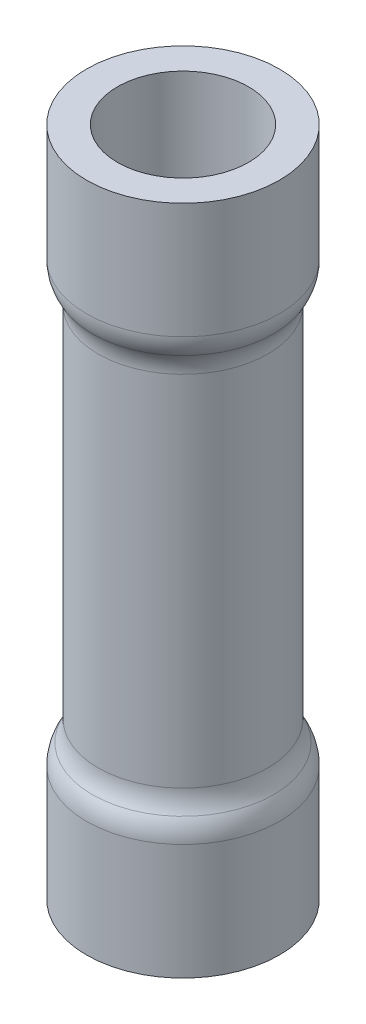
from build123d import *


with BuildPart() as part:
    # Sketch1 → Revolve-Thin1 (revolve)
    with BuildSketch(Plane.XY):
        with BuildLine():
            Line((3.175, 22.098), (3.175, 18.288))
            ThreePointArc((3.175, 18.288), (3.126446888, 17.940196176), (2.9845, 17.618985987))
            ThreePointArc((2.9845, 17.618985987), (2.842553112, 17.297775797), (2.794, 16.949971973))
            Line((2.794, 16.949971973), (2.794, 5.148028027))
            ThreePointArc((2.794, 5.148028027), (2.842553112, 4.800224203), (2.9845, 4.479014013))
            ThreePointArc((2.9845, 4.479014013), (3.126446888, 4.157803824), (3.175, 3.81))
            Line((3.175, 3.81), (3.175, 0))
            Line((3.175, 0), (2.159, 0))
            Line((2.159, 0), (2.159, 3.81))
            ThreePointArc((2.159, 3.81), (2.149289378, 3.879560765), (2.1209, 3.943802803))
            ThreePointArc((2.1209, 3.943802803), (1.865395602, 4.521981143), (1.778, 5.148028027))
            Line((1.778, 5.148028027), (1.778, 16.949971973))
            ThreePointArc((1.778, 16.949971973), (1.865395602, 17.576018857), (2.1209, 18.154197197))
            ThreePointArc((2.1209, 18.154197197), (2.149289378, 18.218439235), (2.159, 18.288))
            Line((2.159, 18.288), (2.159, 22.098))
            Line((2.159, 22.098), (3.175, 22.098))
        make_face()
    revolve(axis=Axis((0, 22.098, 0), (0, -1, 0)))


solid = part.part
